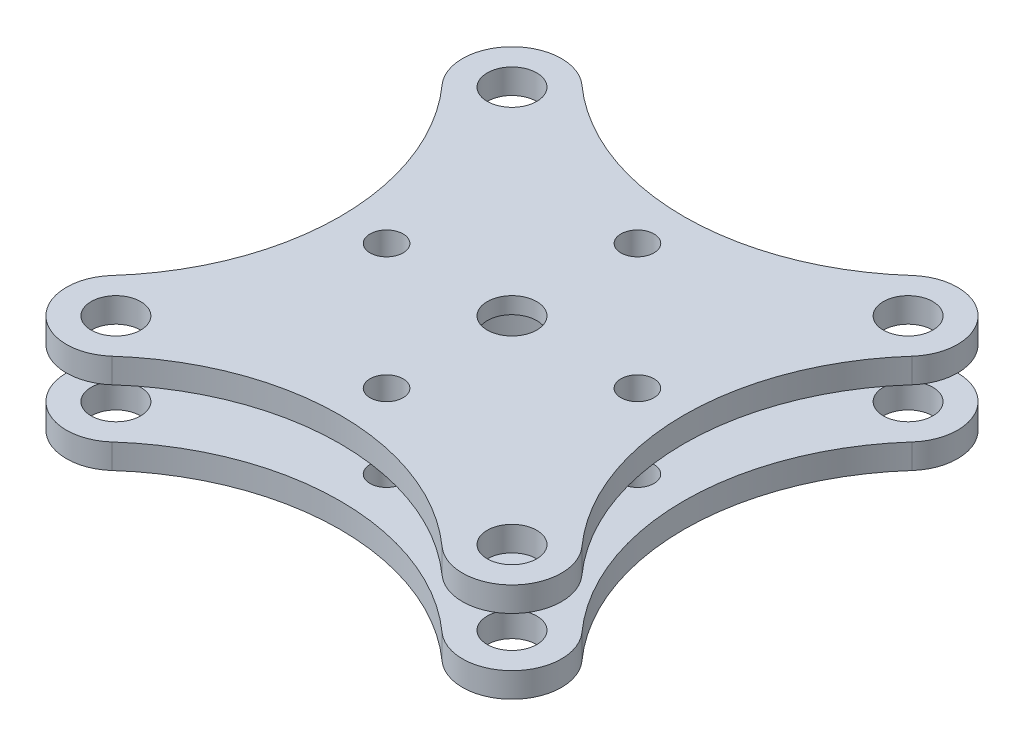
from build123d import *

# Parameters (mm, degrees)
SKETCH1_R           = 27.5
SKETCH1_R_2         = 7.5
SKETCH1_R_3         = 5
BOSS_EXTRUDE1_DEPTH = 7.5
SKETCH2_R           = 27.5
BOSS_EXTRUDE2_DEPTH = 30
SKETCH3_R           = 25.5
CUT_EXTRUDE1_DEPTH  = 25
SKETCH4_R           = 7.5
CUT_EXTRUDE2_DEPTH  = 25


with BuildPart() as part:
    # Sketch1 → Boss-Extrude1 (new body)
    with BuildSketch(Plane(origin=(0, 0, 0), x_dir=(1, 0, 0), z_dir=(0, 1, 0))):
        with BuildLine():
            ThreePointArc((-50, 71.180339887), (-70.606601718, 70.606601718), (-71.180339887, 50))
            ThreePointArc((-71.180339887, 50), (-52.082039325, 0), (-71.180339887, -50))
            ThreePointArc((-71.180339887, -50), (-70.606601718, -70.606601718), (-50, -71.180339887))
            ThreePointArc((-50, -71.180339887), (0, -52.082039325), (50, -71.180339887))
            ThreePointArc((50, -71.180339887), (70.606601718, -70.606601718), (71.180339887, -50))
            ThreePointArc((71.180339887, -50), (52.082039325, 0), (71.180339887, 50))
            ThreePointArc((71.180339887, 50), (70.606601718, 70.606601718), (50, 71.180339887))
            ThreePointArc((50, 71.180339887), (0, 52.082039325), (-50, 71.180339887))
        make_face()
        Circle(SKETCH1_R, mode=Mode.SUBTRACT)
        with Locations((-60, 60)):
            Circle(SKETCH1_R_2, mode=Mode.SUBTRACT)
        with Locations((60, 60)):
            Circle(SKETCH1_R_2, mode=Mode.SUBTRACT)
        with Locations((-60, -60)):
            Circle(SKETCH1_R_2, mode=Mode.SUBTRACT)
        with Locations((60, -60)):
            Circle(SKETCH1_R_2, mode=Mode.SUBTRACT)
        with Locations((0, 38)):
            Circle(SKETCH1_R_3, mode=Mode.SUBTRACT)
        with Locations((-38, 0)):
            Circle(SKETCH1_R_3, mode=Mode.SUBTRACT)
        with Locations((0, -38)):
            Circle(SKETCH1_R_3, mode=Mode.SUBTRACT)
        with Locations((38, 0)):
            Circle(SKETCH1_R_3, mode=Mode.SUBTRACT)
    boss_extrude1 = extrude(amount=-BOSS_EXTRUDE1_DEPTH)

    # Sketch2 → Boss-Extrude2 (add)
    with BuildSketch(Plane(origin=(0, 0, 0), x_dir=(1, 0, 0), z_dir=(0, 1, 0))):
        Circle(SKETCH2_R)
    extrude(amount=-BOSS_EXTRUDE2_DEPTH)

    # Sketch3 → Cut-Extrude1 (cut)
    with BuildSketch(Plane.XZ.offset(30)):
        Circle(SKETCH3_R)
    extrude(amount=-CUT_EXTRUDE1_DEPTH, mode=Mode.SUBTRACT)

    # Sketch4 → Cut-Extrude2 (cut)
    with BuildSketch(Plane.XZ.offset(5)):
        Circle(SKETCH4_R)
    extrude(amount=-CUT_EXTRUDE2_DEPTH, mode=Mode.SUBTRACT)

    # Mirror1: Boss-Extrude1 across plane
    add(boss_extrude1.mirror(Plane.ZX.offset(-15)))


solid = part.part
